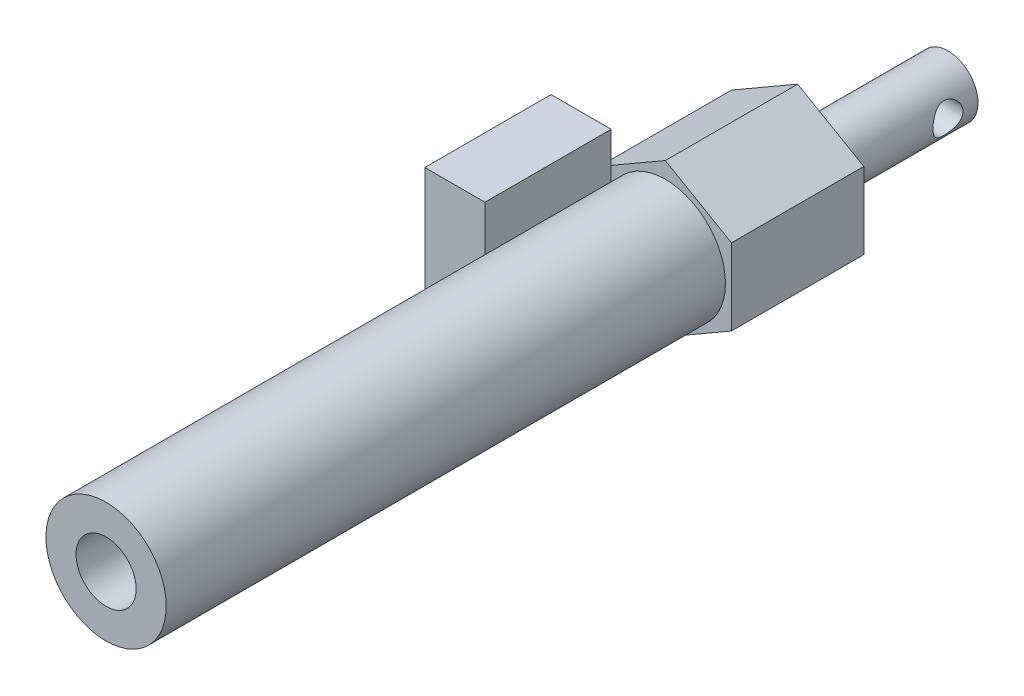
from build123d import *

# Parameters (mm, degrees)
SKETCH1_R               = 10
BOSS_EXTRUDE1_DEPTH     = 115
SKETCH2_R               = 5
BOSS_EXTRUDE2_DEPTH     = 25
SKETCH3_R               = 5
CUT_EXTRUDE1_DEPTH      = 110
SKETCH4_R               = 2.5
CUT_EXTRUDE2_DEPTH      = 11
CUT_EXTRUDE2_DEPTH_BACK = 11
SKETCH5_R               = 10
BOSS_EXTRUDE3_DEPTH     = 22
SKETCH6_W               = 21
SKETCH6_H               = 21
BOSS_EXTRUDE4_DEPTH     = 8
SKETCH7_W               = 21
SKETCH7_H               = 21
BOSS_EXTRUDE5_DEPTH     = 2
SKETCH8_R               = 5
SKETCH8_R_2             = 4
CUT_EXTRUDE3_DEPTH      = 2
SKETCH9_R               = 1.545135807
CUT_EXTRUDE4_DEPTH      = 2


with BuildPart() as part:
    # Sketch1 → Boss-Extrude1 (new body)
    with BuildSketch(Plane.XY):
        Circle(SKETCH1_R)
    extrude(amount=BOSS_EXTRUDE1_DEPTH)

    # Sketch2 → Boss-Extrude2 (add)
    with BuildSketch(Plane(origin=(0, 0, 0), x_dir=(-1, 0, 0), z_dir=(0, 0, -1))):
        Circle(SKETCH2_R)
    extrude(amount=BOSS_EXTRUDE2_DEPTH)

    # Sketch3 → Cut-Extrude1 (cut)
    with BuildSketch(Plane.XY.offset(115)):
        Circle(SKETCH3_R)
    extrude(amount=-CUT_EXTRUDE1_DEPTH, mode=Mode.SUBTRACT)

    # Sketch4 → Cut-Extrude2 (cut, two sides)
    with BuildSketch(Plane(origin=(0, 0, 0), x_dir=(0, 0, -1), z_dir=(1, 0, 0))) as cut_extrude2_sk:
        with Locations((20, 0)):
            Circle(SKETCH4_R)
    extrude(amount=CUT_EXTRUDE2_DEPTH, mode=Mode.SUBTRACT)
    extrude(cut_extrude2_sk.sketch, amount=-CUT_EXTRUDE2_DEPTH_BACK, mode=Mode.SUBTRACT)

    # Sketch5 → Boss-Extrude3 (add)
    with BuildSketch(Plane(origin=(0, 0, 0), x_dir=(-1, 0, 0), z_dir=(0, 0, -1))):
        Polygon((0, -12.701705922), (11, -6.350852961), (11, 6.350852961), (0, 12.701705922), (-11, 6.350852961), (-11, -6.350852961), align=None)
        Circle(SKETCH5_R, mode=Mode.SUBTRACT)
    extrude(amount=-BOSS_EXTRUDE3_DEPTH)



with BuildPart() as body_2:
    # Sketch6 → Boss-Extrude4 (new body)
    with BuildSketch(Plane.ZY.offset(11)):
        with Locations((32.5, 2.201705922)):
            Rectangle(SKETCH6_W, SKETCH6_H)
    extrude(amount=BOSS_EXTRUDE4_DEPTH)


with BuildPart() as part_1:
    add(part.part)

    add(body_2.part)  # Boss-Extrude5 merges body 2
    # Sketch7 → Boss-Extrude5 (add)
    with BuildSketch(Plane(origin=(-11, 0, 0), x_dir=(0, 0, -1), z_dir=(1, 0, 0))):
        with Locations((-32.5, 2.201705922)):
            Rectangle(SKETCH7_W, SKETCH7_H)
    extrude(amount=BOSS_EXTRUDE5_DEPTH)

    # Sketch8 → Cut-Extrude3 (cut)
    with BuildSketch(Plane.ZY.offset(19)):
        with Locations((36.5, 6.201705922)):
            Circle(SKETCH8_R)
        with Locations((36.5, 6.201705922)):
            Circle(SKETCH8_R_2, mode=Mode.SUBTRACT)
    extrude(amount=-CUT_EXTRUDE3_DEPTH, mode=Mode.SUBTRACT)

    # Sketch9 → Cut-Extrude4 (cut)
    with BuildSketch(Plane.ZY.offset(19)):
        with Locations((36.5, 6.201705922)):
            Circle(SKETCH9_R)
    extrude(amount=-CUT_EXTRUDE4_DEPTH, mode=Mode.SUBTRACT)


solid = part_1.part
